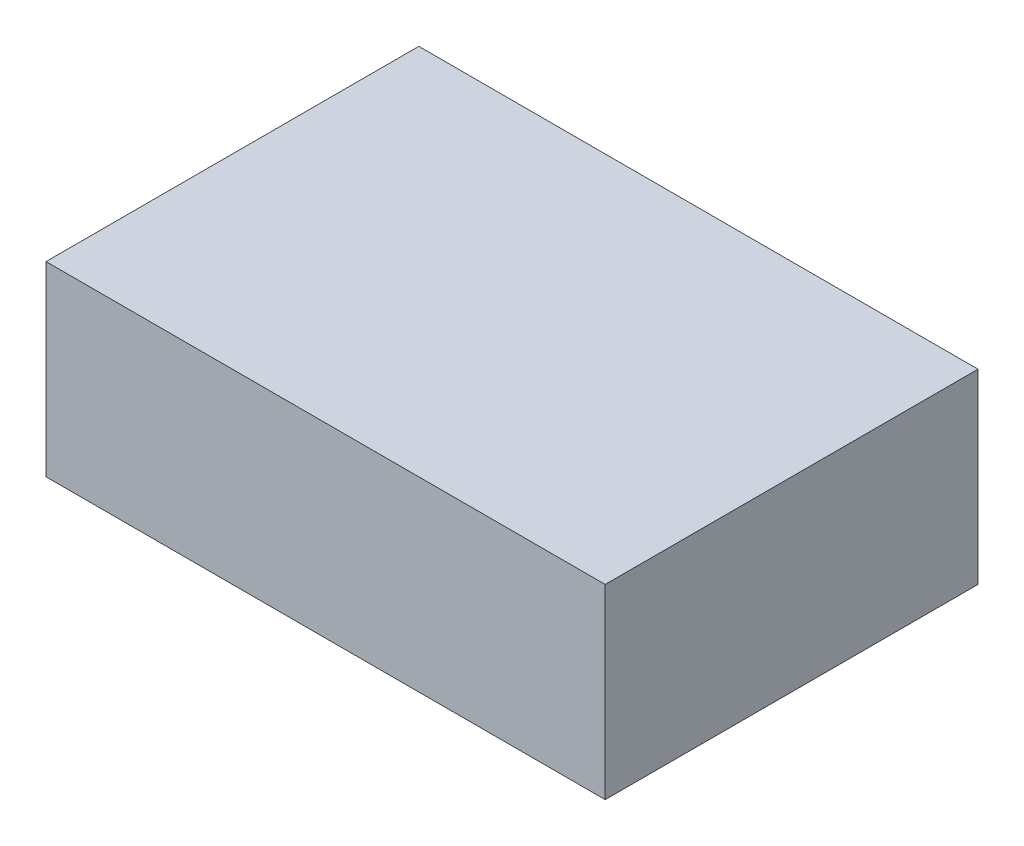
from build123d import *

# Parameters (mm, degrees)
SKETCH1_W           = 304.8
SKETCH1_H           = 203.2
BOSS_EXTRUDE1_DEPTH = 101.6


with BuildPart() as part:
    # Sketch1 → Boss-Extrude1 (new body)
    with BuildSketch(Plane(origin=(0, 0, 0), x_dir=(1, 0, 0), z_dir=(0, 1, 0))):
        Rectangle(SKETCH1_W, SKETCH1_H)
    extrude(amount=BOSS_EXTRUDE1_DEPTH)


solid = part.part
